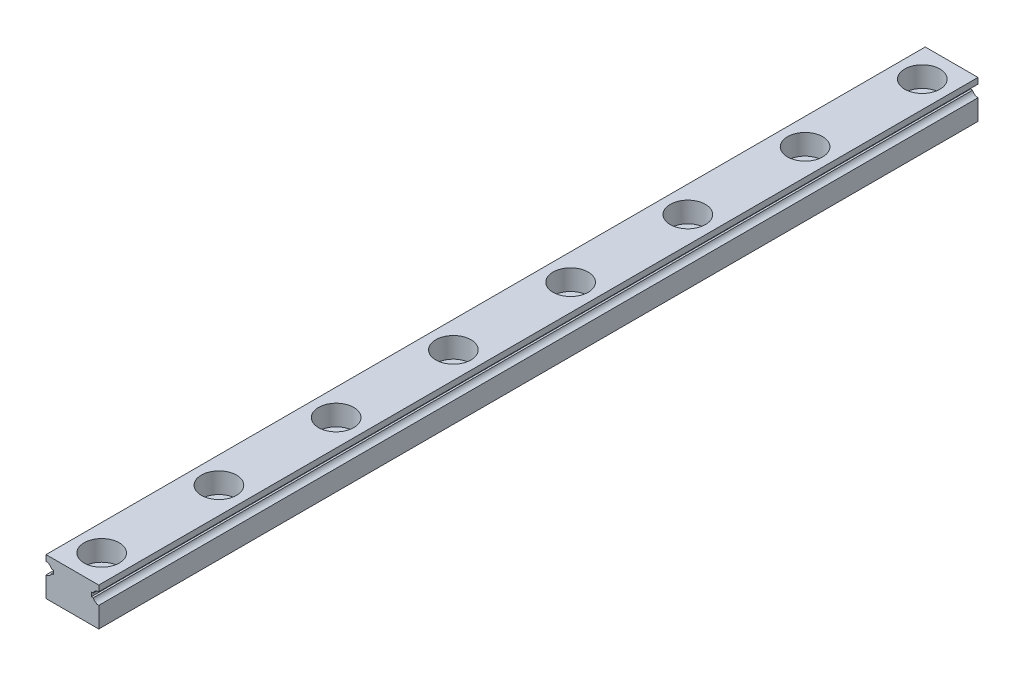
from build123d import *

# Parameters (mm, degrees)
EXTRUDE1_DEPTH  = 150
SKETCH2_R       = 3
EXTRUDE2_DEPTH  = 3.5
SKETCH_R        = 1.75
EXTRUDE3_DEPTH  = 151.208188858
LPATTERN1_COUNT = 13
LPATTERN1_PITCH = 20


with BuildPart() as part:
    # Sketch1 → Extrude1 (new body)
    with BuildSketch(Plane.XY):
        with BuildLine():
            Line((-4.5, -3.25), (4.5, -3.25))
            Line((4.5, -3.25), (4.5, 0.25))
            ThreePointArc((4.5, 0.25), (3.93077967, 0.427814974), (3.563991137, 0.898023568))
            Line((3.563991137, 0.898023568), (3.235073025, 0.898023568))
            Line((3.235073025, 0.898023568), (3.235073025, 1.601976432))
            Line((3.235073025, 1.601976432), (3.563991137, 1.601976432))
            ThreePointArc((3.563991137, 1.601976432), (3.93077967, 2.072185026), (4.5, 2.25))
            Line((4.5, 2.25), (4.5, 3.25))
            Line((4.5, 3.25), (-4.5, 3.25))
            Line((-4.5, 3.25), (-4.5, 2.25))
            ThreePointArc((-4.5, 2.25), (-3.93077967, 2.072185026), (-3.563991137, 1.601976432))
            Line((-3.563991137, 1.601976432), (-3.235073025, 1.601976432))
            Line((-3.235073025, 1.601976432), (-3.235073025, 0.898023568))
            Line((-3.235073025, 0.898023568), (-3.563991137, 0.898023568))
            ThreePointArc((-3.563991137, 0.898023568), (-3.93077967, 0.427814974), (-4.5, 0.25))
            Line((-4.5, 0.25), (-4.5, -3.25))
        make_face()
    extrude(amount=EXTRUDE1_DEPTH)

    # Sketch2 → Extrude2 (cut)
    with BuildSketch(Plane(origin=(0, 3.25, 0), x_dir=(1, 0, 0), z_dir=(0, 1, 0))):
        with Locations((0, -5)):
            Circle(SKETCH2_R)
    extrude2 = extrude(amount=-EXTRUDE2_DEPTH, mode=Mode.SUBTRACT)

    # Sketch → Extrude3 (cut, through all)
    with BuildSketch(Plane(origin=(0, 3.25, 0), x_dir=(1, 0, 0), z_dir=(0, 1, 0))):
        with Locations((0, -5)):
            Circle(SKETCH_R)
    extrude3 = extrude(amount=-EXTRUDE3_DEPTH, mode=Mode.SUBTRACT)

    # LPattern1: Extrude2, Extrude3 ×13
    with Locations(*[(0, 0, i * LPATTERN1_PITCH) for i in range(1, LPATTERN1_COUNT)]):
        add(extrude2, mode=Mode.SUBTRACT)
        add(extrude3, mode=Mode.SUBTRACT)


solid = part.part
